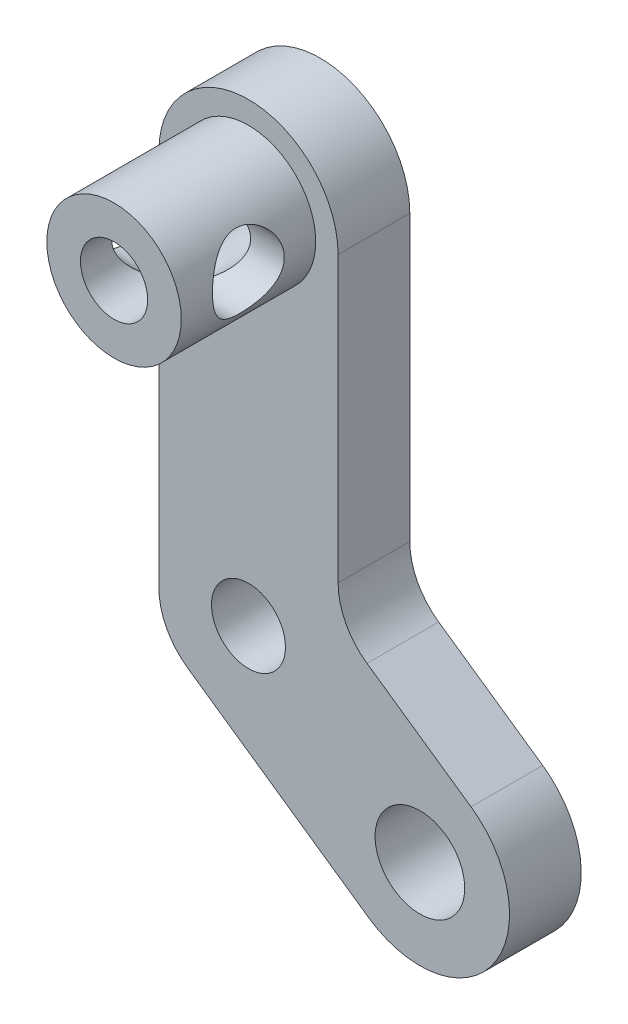
from build123d import *

# Parameters (mm, degrees)
SKETCH1_R                                       = 2
SKETCH1_R_2                                     = 1.65
BOSS_EXTRUDE1_DEPTH                             = 3.2
SKETCH5_R                                       = 3
BOSS_EXTRUDE2_DEPTH                             = 6
CSK_FOR_M3_FLAT_HEAD_MACHINE_SCREW2_D           = 3
CSK_FOR_M3_FLAT_HEAD_MACHINE_SCREW2_CSINK_D     = 6
CSK_FOR_M3_FLAT_HEAD_MACHINE_SCREW2_CSINK_ANGLE = 90
SKETCH8_R                                       = 1.6
CUT_EXTRUDE2_DEPTH                              = 16


with BuildPart() as part:
    # Sketch1 → Boss-Extrude1 (new body)
    with BuildSketch(Plane.XY):
        with BuildLine():
            Line((-4, -0.523005645), (-4, 16.35))
            ThreePointArc((-4, 16.35), (0, 20.35), (4, 16.35))
            Line((4, 16.35), (4, 3.661039513))
            ThreePointArc((4, 3.661039513), (4.341627544, 2.270695713), (5.288703922, 1.197005071))
            Line((5.288703922, 1.197005071), (9.931728104, -2.027620743))
            ThreePointArc((9.931728104, -2.027620743), (10.935379257, -7.594728104), (5.368271896, -8.598379257))
            Line((5.368271896, -8.598379257), (-2.711296078, -2.987040087))
            ThreePointArc((-2.711296078, -2.987040087), (-3.658372456, -1.913349445), (-4, -0.523005645))
        make_face()
        with Locations((7.65, -5.313)):
            Circle(SKETCH1_R, mode=Mode.SUBTRACT)
        Circle(SKETCH1_R_2, mode=Mode.SUBTRACT)
    extrude(amount=BOSS_EXTRUDE1_DEPTH)

    # Sketch5 → Boss-Extrude2 (add)
    with BuildSketch(Plane.XY.offset(3.2)):
        with Locations((0, 16.35)):
            Circle(SKETCH5_R)
    extrude(amount=BOSS_EXTRUDE2_DEPTH)

    # CSK for M3 Flat Head Machine Screw2 (through all)
    with Locations(Plane(origin=(0, 0, 0), x_dir=(-1, 0, 0), z_dir=(0, 0, -1))):
        with Locations((0, 16.35)):
            CounterSinkHole(CSK_FOR_M3_FLAT_HEAD_MACHINE_SCREW2_D / 2, CSK_FOR_M3_FLAT_HEAD_MACHINE_SCREW2_CSINK_D / 2, counter_sink_angle=CSK_FOR_M3_FLAT_HEAD_MACHINE_SCREW2_CSINK_ANGLE)

    # Sketch8 → Cut-Extrude2 (cut)
    with BuildSketch(Plane(origin=(4, 0, 0), x_dir=(0, 0, -1), z_dir=(1, 0, 0))):
        with Locations((-6.2, 16.5)):
            Circle(SKETCH8_R)
    extrude(amount=-CUT_EXTRUDE2_DEPTH, mode=Mode.SUBTRACT)


solid = part.part
